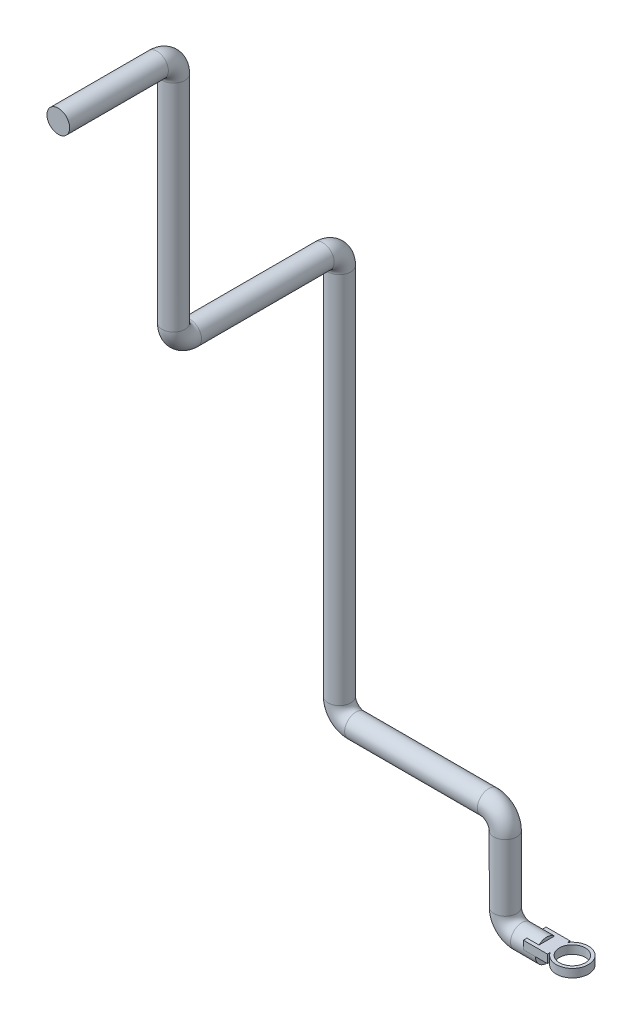
from build123d import *

# Parameters (mm, degrees)
CROQUIS1_R              = 13.7
CROQUIS2_R              = 19.386232946
CROQUIS2_R_2            = 15.569283249
SALIENTE_EXTRUIR1_DEPTH = 10
CROQUIS3_W              = 29.024267222
CROQUIS3_H              = 27.405549086
SALIENTE_EXTRUIR2_DEPTH = 10


with BuildPart() as part:
    # Barrer1: sweep along a curve in space
    with BuildLine() as barrer1_path:
        Line((0, 0, 0), (-30, 0, 0))
        ThreePointArc((-30, 0, 0), (-44.142135624, 5.857864376, 0), (-50, 20, 0))
        Line((-50, 20, 0), (-50, 100, 0))
        ThreePointArc((-50, 100, 0), (-55.857864376, 114.142135624, 0), (-70, 120, 0))
        Line((-70, 120, 0), (-230, 120, 0))
        ThreePointArc((-230, 120, 0), (-244.142135624, 125.857864376, 0), (-250, 140, 0))
        Line((-250, 140, 0), (-250, 590.01, 0))
        ThreePointArc((-250, 590.01, 0), (-250, 604.152135624, 5.857864376), (-250, 610.01, 20))
        Line((-250, 610.01, 20), (-250, 610.01, 180))
        ThreePointArc((-250, 610.01, 180), (-250, 615.867864376, 194.142135624), (-250, 630.01, 200))
        Line((-250, 630.01, 200), (-250, 890.01, 200))
        ThreePointArc((-250, 890.01, 200), (-250, 904.152135624, 205.857864376), (-250, 910.01, 220))
        Line((-250, 910.01, 220), (-250, 910.01, 339))
    # Croquis1 → Barrer1 (sweep)
    with BuildSketch(Plane(origin=(0, 0, 0), x_dir=(0, 0, -1), z_dir=(1, 0, 0))):
        Circle(CROQUIS1_R)
    sweep(path=barrer1_path.line)



with BuildPart() as body_2:
    # Croquis2 → Saliente-Extruir1 (new body)
    with BuildSketch(Plane(origin=(0, 0, 0), x_dir=(1, 0, 0), z_dir=(0, 1, 0))):
        with Locations((30.852076519, 0)):
            Circle(CROQUIS2_R)
        with Locations((30.852076519, 0)):
            Circle(CROQUIS2_R_2, mode=Mode.SUBTRACT)
    extrude(amount=SALIENTE_EXTRUIR1_DEPTH)


with BuildPart() as part_1:
    add(part.part)

    add(body_2.part)  # Saliente-Extruir2 merges body 2
    # Croquis3 → Saliente-Extruir2 (add)
    with BuildSketch(Plane(origin=(0, 0, 0), x_dir=(1, 0, 0), z_dir=(0, 1, 0))):
        Rectangle(CROQUIS3_W, CROQUIS3_H)
    extrude(amount=SALIENTE_EXTRUIR2_DEPTH)


solid = part_1.part
